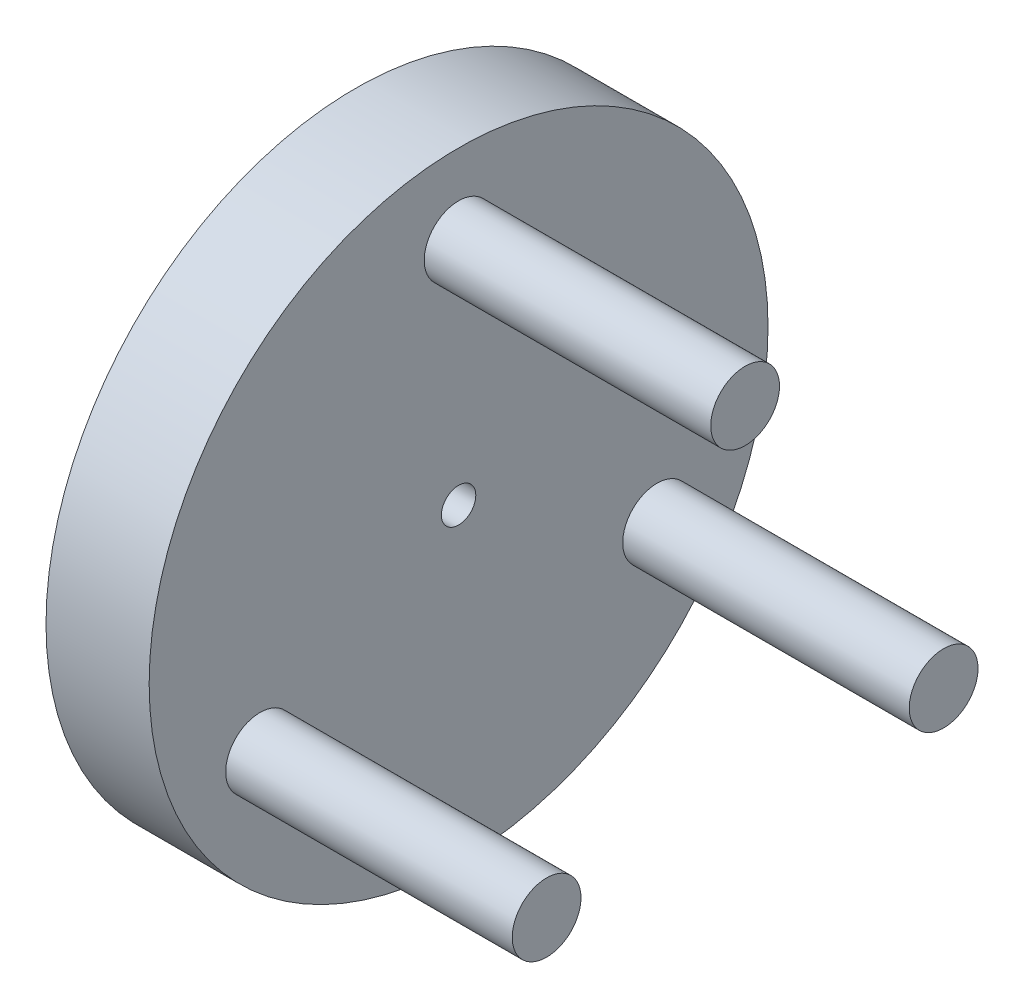
from build123d import *

# Parameters (mm, degrees)
SKETCH1_R           = 27
SKETCH1_R_2         = 2.8
BOSS_EXTRUDE2_DEPTH = 4
SKETCH2_R           = 27
SKETCH2_R_2         = 2.8
SKETCH2_R_3         = 1.5
BOSS_EXTRUDE3_DEPTH = 5
SKETCH3_R           = 3
BOSS_EXTRUDE4_DEPTH = 25
SKETCH4_R           = 12.2
SKETCH4_R_2         = 7.64
BOSS_EXTRUDE5_DEPTH = 3
SKETCH5_R           = 12.2
SKETCH5_R_2         = 7.64
CUT_EXTRUDE1_DEPTH  = 3


with BuildPart() as part:
    # Sketch1 → Boss-Extrude2 (new body)
    with BuildSketch(Plane(origin=(0, 0, 0), x_dir=(0, 0, -1), z_dir=(1, 0, 0))):
        Circle(SKETCH1_R)
        Circle(SKETCH1_R_2, mode=Mode.SUBTRACT)
    extrude(amount=BOSS_EXTRUDE2_DEPTH)

    # Sketch2 → Boss-Extrude3 (add)
    with BuildSketch(Plane(origin=(4, 0, 0), x_dir=(0, 0, -1), z_dir=(1, 0, 0))):
        Circle(SKETCH2_R)
        Circle(SKETCH2_R_2, mode=Mode.SUBTRACT)
        Circle(SKETCH2_R_2)
        Circle(SKETCH2_R_3, mode=Mode.SUBTRACT)
    extrude(amount=BOSS_EXTRUDE3_DEPTH)

    # Sketch3 → Boss-Extrude4 (add)
    with BuildSketch(Plane(origin=(9, 0, 0), x_dir=(0, 0, -1), z_dir=(1, 0, 0))):
        with Locations((0, 20)):
            Circle(SKETCH3_R)
        with Locations((17.320508076, -10)):
            Circle(SKETCH3_R)
        with Locations((-17.320508076, -10)):
            Circle(SKETCH3_R)
    extrude(amount=BOSS_EXTRUDE4_DEPTH)

    # Sketch4 → Boss-Extrude5 (add)
    with BuildSketch(Plane(origin=(9, 0, 0), x_dir=(0, 0, -1), z_dir=(1, 0, 0))):
        Circle(SKETCH4_R)
        Circle(SKETCH4_R_2, mode=Mode.SUBTRACT)
    extrude(amount=BOSS_EXTRUDE5_DEPTH)

    # Sketch5 → Cut-Extrude1 (cut)
    with BuildSketch(Plane(origin=(12, 0, 0), x_dir=(0, 0, -1), z_dir=(1, 0, 0))):
        Circle(SKETCH5_R)
        Circle(SKETCH5_R_2, mode=Mode.SUBTRACT)
    extrude(amount=-CUT_EXTRUDE1_DEPTH, mode=Mode.SUBTRACT)


solid = part.part
